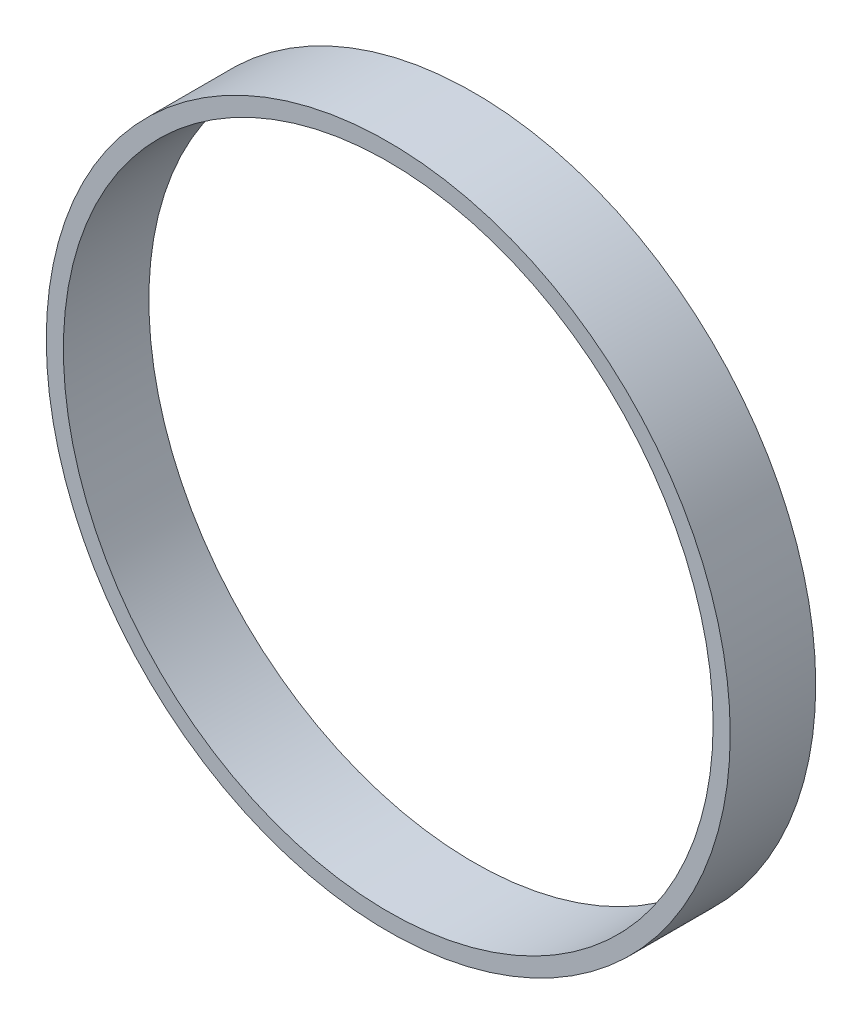
from build123d import *

# Parameters (mm, degrees)
SKETCH1_R           = 40
SKETCH1_R_2         = 38
BOSS_EXTRUDE1_DEPTH = 10


with BuildPart() as part:
    # Sketch1 → Boss-Extrude1 (new body)
    with BuildSketch(Plane.XY):
        Circle(SKETCH1_R)
        Circle(SKETCH1_R_2, mode=Mode.SUBTRACT)
    extrude(amount=BOSS_EXTRUDE1_DEPTH)


solid = part.part
